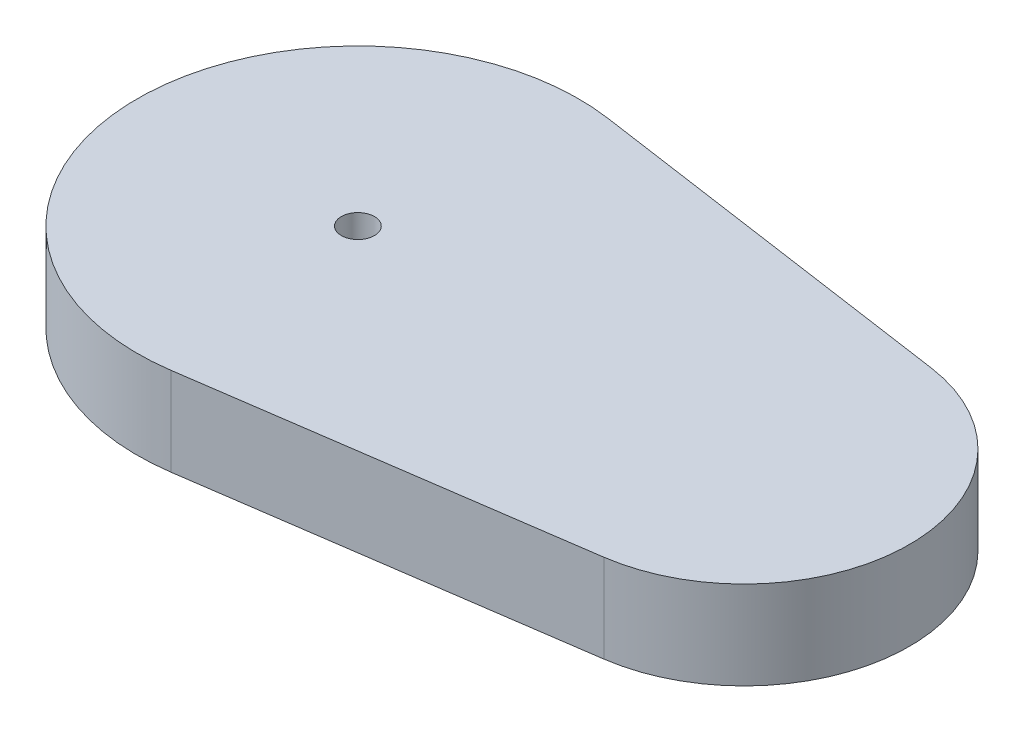
from build123d import *

# Parameters (mm, degrees)
SKETCH1_R           = 0.6
BOSS_EXTRUDE1_DEPTH = 3.2


with BuildPart() as part:
    # Sketch1 → Boss-Extrude1 (new body)
    with BuildSketch(Plane(origin=(0, 0, 0), x_dir=(1, 0, 0), z_dir=(0, 1, 0))):
        with BuildLine():
            Line((1.142857143, -7.917946549), (14.857142857, -5.938459912))
            ThreePointArc((14.857142857, -5.938459912), (20, 0), (14.857142857, 5.938459912))
            Line((14.857142857, 5.938459912), (1.142857143, 7.917946549))
            ThreePointArc((1.142857143, 7.917946549), (-8, 0), (1.142857143, -7.917946549))
        make_face()
        Circle(SKETCH1_R, mode=Mode.SUBTRACT)
    extrude(amount=BOSS_EXTRUDE1_DEPTH)


solid = part.part
